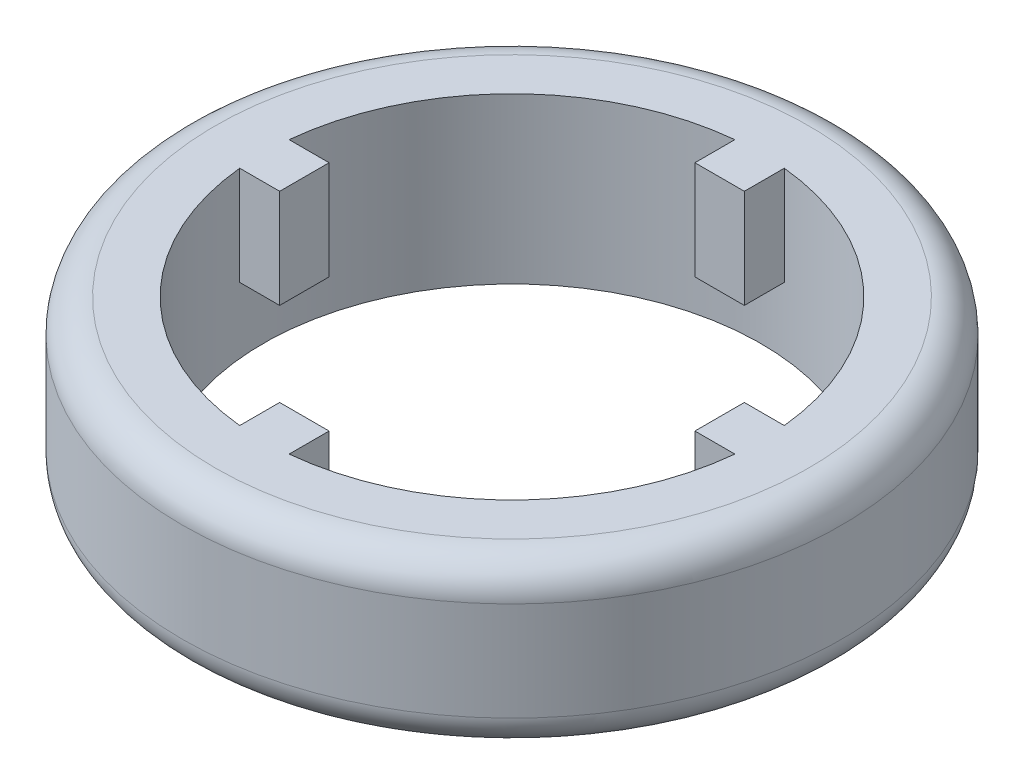
from build123d import *

# Parameters (mm, degrees)
SKETCH_1_R      = 20
SKETCH_1_R_2    = 15.1
EXTRUDE_1_DEPTH = 10
FILLET_1_R      = 2
SKETCH_2_W      = 3
SKETCH_2_H      = 5
SKETCH_2_W_2    = 5
SKETCH_2_H_2    = 3
EXTRUDE_2_DEPTH = 6


with BuildPart() as part:
    # Эскиз1 → Бобышка-Вытянуть1 (new body)
    with BuildSketch(Plane(origin=(0, 0, 0), x_dir=(1, 0, 0), z_dir=(0, 1, 0))):
        Circle(SKETCH_1_R)
        Circle(SKETCH_1_R_2, mode=Mode.SUBTRACT)
    extrude(amount=EXTRUDE_1_DEPTH)

    # Скругление1
    fillet_1_edges = [part.edges().sort_by_distance(p)[0] for p in [
        (-20, 0, 0),
        (-20, 10, 0),
    ]]
    fillet(fillet_1_edges, radius=FILLET_1_R)

    # Эскиз2 → Бобышка-Вытянуть2 (add)
    with BuildSketch(Plane(origin=(0, 10, 0), x_dir=(1, 0, 0), z_dir=(0, 1, 0))):
        with Locations((0, 15.1)):
            Rectangle(SKETCH_2_W, SKETCH_2_H)
        with Locations((-15.1, 0)):
            Rectangle(SKETCH_2_W_2, SKETCH_2_H_2)
        with Locations((15.1, 0)):
            Rectangle(SKETCH_2_W_2, SKETCH_2_H_2)
        with Locations((0, -15.1)):
            Rectangle(SKETCH_2_W, SKETCH_2_H)
    extrude(amount=-EXTRUDE_2_DEPTH)


solid = part.part
